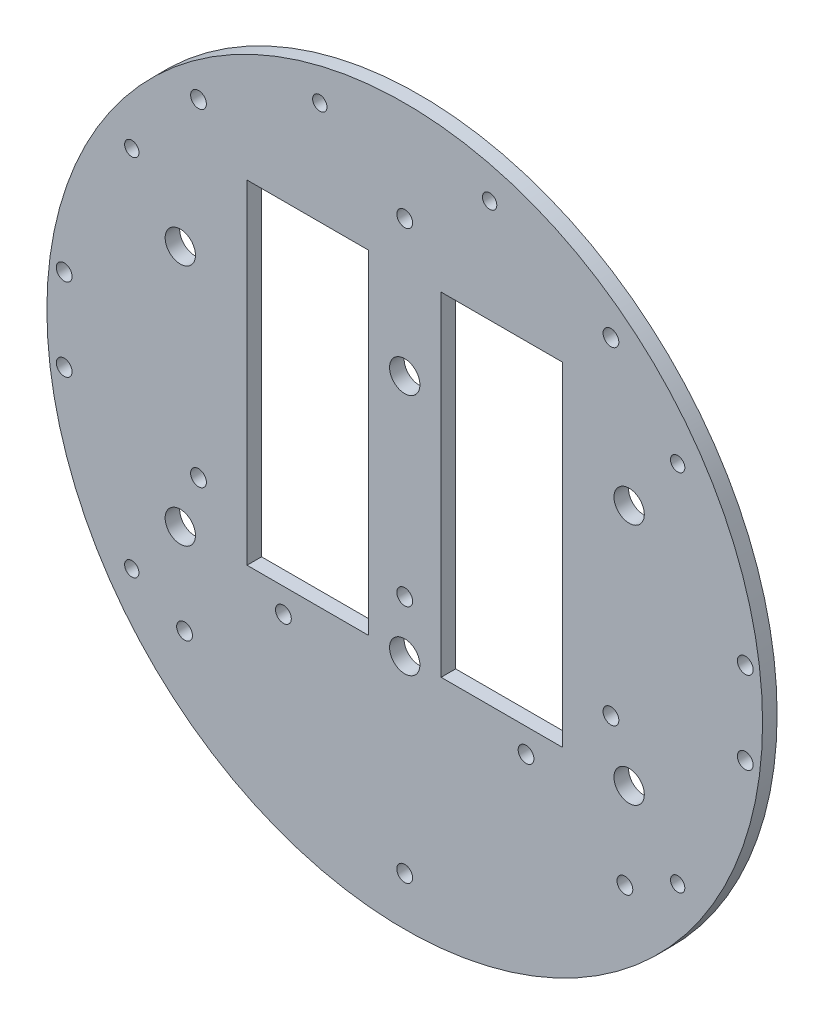
from build123d import *

# Parameters (mm, degrees)
SKETCH1_R                = 1.651
BOSS_EXTRUDE2_DEPTH      = 3.048
SKETCH5_W                = 36.105919561
SKETCH5_H                = 30.801250688
SKETCH5_W_2              = 35.958513686
SKETCH5_H_2              = 33.469345806
BOSS_EXTRUDE4_DEPTH      = 3.048
SKETCH11_R               = 1.651
CUT_EXTRUDE7_DEPTH       = 106.247375758
BOSS_EXTRUDE6_DEPTH      = 3.048
SKETCH14_W               = 25.4
SKETCH14_H               = 69.85
CUT_EXTRUDE9_DEPTH       = 46.482
SKETCH15_R               = 1.651
CUT_EXTRUDE10_DEPTH      = 150.876
SKETCH16_R               = 1.5
CUT_EXTRUDE11_DEPTH      = 107.010848992
SKETCH17_R               = 3.175
CUT_EXTRUDE12_DEPTH      = 103.378
CUT_EXTRUDE12_DEPTH_BACK = 48.768


with BuildPart() as part:
    # Sketch1 → Boss-Extrude2 (new body)
    with BuildSketch(Plane.XY):
        with BuildLine():
            Line((-73.845886141, 12.7), (-56.065886141, 12.7))
            Line((-56.065886141, 12.7), (-56.065886141, -12.7))
            Line((-56.065886141, -12.7), (-73.845886141, -12.7))
            ThreePointArc((-73.845886141, -12.7), (0, -74.93), (73.845886141, -12.7))
            Line((73.845886141, -12.7), (56.065886141, -12.7))
            Line((56.065886141, -12.7), (56.065886141, 12.7))
            Line((56.065886141, 12.7), (73.845886141, 12.7))
            ThreePointArc((73.845886141, 12.7), (0, 74.93), (-73.845886141, 12.7))
        make_face()
        with Locations(Location((-45.466, 11.049, 0), (0, 0, 180))):
            Circle(SKETCH1_R, mode=Mode.SUBTRACT)
        with Locations(Location((-20.067270032, 10.795, 0), (0, 0, 180))):
            Circle(SKETCH1_R, mode=Mode.SUBTRACT)
        with Locations(Location((-20.067270032, -10.795, 0), (0, 0, 180))):
            Circle(SKETCH1_R, mode=Mode.SUBTRACT)
        with Locations(Location((-45.466, -11.049, 0), (0, 0, 180))):
            Circle(SKETCH1_R, mode=Mode.SUBTRACT)
        with Locations(Location((45.466, -11.049, 0), (0, 0, 180))):
            Circle(SKETCH1_R, mode=Mode.SUBTRACT)
        with Locations(Location((20.067270032, -10.795, 0), (0, 0, 180))):
            Circle(SKETCH1_R, mode=Mode.SUBTRACT)
        with Locations(Location((20.067270032, 10.795, 0), (0, 0, 180))):
            Circle(SKETCH1_R, mode=Mode.SUBTRACT)
        with Locations(Location((45.466, 11.049, 0), (0, 0, 180))):
            Circle(SKETCH1_R, mode=Mode.SUBTRACT)
    extrude(amount=BOSS_EXTRUDE2_DEPTH)

    # Sketch5 → Boss-Extrude4 (add)
    with BuildSketch(Plane(origin=(0, 0, 0), x_dir=(-1, 0, 0), z_dir=(0, 0, -1))):
        with Locations((34.78484389, -0.38515144)):
            Rectangle(SKETCH5_W, SKETCH5_H)
        with Locations((-32.830563904, 0.948896119)):
            Rectangle(SKETCH5_W_2, SKETCH5_H_2)
    extrude(amount=-BOSS_EXTRUDE4_DEPTH)

    # Sketch11 → Cut-Extrude7 (cut, through all)
    with BuildSketch(Plane(origin=(0, 0, 0), x_dir=(-1, 0, 0), z_dir=(0, 0, -1))):
        with Locations((43.18, 53.975)):
            Circle(SKETCH11_R)
        with Locations((0, 53.975)):
            Circle(SKETCH11_R)
        with Locations((0, -14.605)):
            Circle(SKETCH11_R)
        with Locations((43.18, -14.605)):
            Circle(SKETCH11_R)
        with Locations((-43.18, 53.975)):
            Circle(SKETCH11_R)
        with Locations((-43.18, -14.605)):
            Circle(SKETCH11_R)
        with Locations((-25.4, -30.48)):
            Circle(SKETCH11_R)
        with Locations((-46.101, -43.8609994)):
            Circle(SKETCH11_R)
        with Locations((46.101, -43.8609994)):
            Circle(SKETCH11_R)
        with Locations((0, -64.77)):
            Circle(SKETCH11_R)
        with Locations((25.4, -30.48)):
            Circle(SKETCH11_R)
    extrude(amount=-CUT_EXTRUDE7_DEPTH, mode=Mode.SUBTRACT)

    # Sketch12 → Boss-Extrude6 (add)
    with BuildSketch(Plane(origin=(0, 0, 0), x_dir=(-1, 0, 0), z_dir=(0, 0, -1))):
        with BuildLine():
            Line((-54.995250635, 50.892310889), (-54.566459663, -51.351790425))
            ThreePointArc((-54.566459663, -51.351790425), (-74.929341077, -0.314238422), (-54.995250635, 50.892310889))
        make_face()
        with BuildLine():
            Line((54.995250635, 50.892310889), (54.995250635, -50.892310889))
            ThreePointArc((54.995250635, -50.892310889), (74.93, 0), (54.995250635, 50.892310889))
        make_face()
    extrude(amount=-BOSS_EXTRUDE6_DEPTH)

    # Sketch14 → Cut-Extrude9 (cut)
    with BuildSketch(Plane(origin=(0, 0, 0), x_dir=(-1, 0, 0), z_dir=(0, 0, -1))):
        with Locations((-20.32, 9.525)):
            Rectangle(SKETCH14_W, SKETCH14_H)
        with Locations((20.32, 9.525)):
            Rectangle(SKETCH14_W, SKETCH14_H)
    extrude(amount=-CUT_EXTRUDE9_DEPTH, mode=Mode.SUBTRACT)

    # Sketch15 → Cut-Extrude10 (cut)
    with BuildSketch(Plane(origin=(-30.092005081, 4.08352975, -68.453), x_dir=(-1, 0, 0), z_dir=(0, 0, -1))):
        with Locations(Location((-101.395980802, -12.71952975, 0), (0, 0, 180))):
            Circle(SKETCH15_R)
        with Locations(Location((-101.395980802, 4.55247025, 0), (0, 0, 180))):
            Circle(SKETCH15_R)
        with Locations(Location((41.211970641, -12.71952975, 0), (0, 0, 180))):
            Circle(SKETCH15_R)
        with Locations(Location((41.211970641, 4.55247025, 0), (0, 0, 180))):
            Circle(SKETCH15_R)
    extrude(amount=-CUT_EXTRUDE10_DEPTH, mode=Mode.SUBTRACT)

    # Sketch16 → Cut-Extrude11 (cut, through all)
    with BuildSketch(Plane(origin=(0, 0, 0), x_dir=(-1, 0, 0), z_dir=(0, 0, -1))):
        with Locations((-17.78, 66.04)):
            Circle(SKETCH16_R)
        with Locations((-57.15, 38.1)):
            Circle(SKETCH16_R)
        with Locations((17.78, 66.04)):
            Circle(SKETCH16_R)
        with Locations((-57.15, -38.1)):
            Circle(SKETCH16_R)
        with Locations((57.15, -38.1)):
            Circle(SKETCH16_R)
        with Locations((57.15, 38.1)):
            Circle(SKETCH16_R)
    extrude(amount=-CUT_EXTRUDE11_DEPTH, mode=Mode.SUBTRACT)

    # Sketch17 → Cut-Extrude12 (cut, two sides)
    with BuildSketch(Plane(origin=(-30.092005081, 4.08352975, -57.658), x_dir=(1, 0, 0), z_dir=(0, 0, 1))) as cut_extrude12_sk:
        with Locations((-16.897994919, 21.31647025)):
            Circle(SKETCH17_R)
        with Locations((77.082005081, 21.31647025)):
            Circle(SKETCH17_R)
        with Locations((30.092005081, 21.31647025)):
            Circle(SKETCH17_R)
        with Locations((77.082005081, -29.48352975)):
            Circle(SKETCH17_R)
        with Locations((30.092005081, -29.48352975)):
            Circle(SKETCH17_R)
        with Locations((-16.897994919, -29.48352975)):
            Circle(SKETCH17_R)
    extrude(amount=CUT_EXTRUDE12_DEPTH, mode=Mode.SUBTRACT)
    extrude(cut_extrude12_sk.sketch, amount=-CUT_EXTRUDE12_DEPTH_BACK, mode=Mode.SUBTRACT)


solid = part.part
